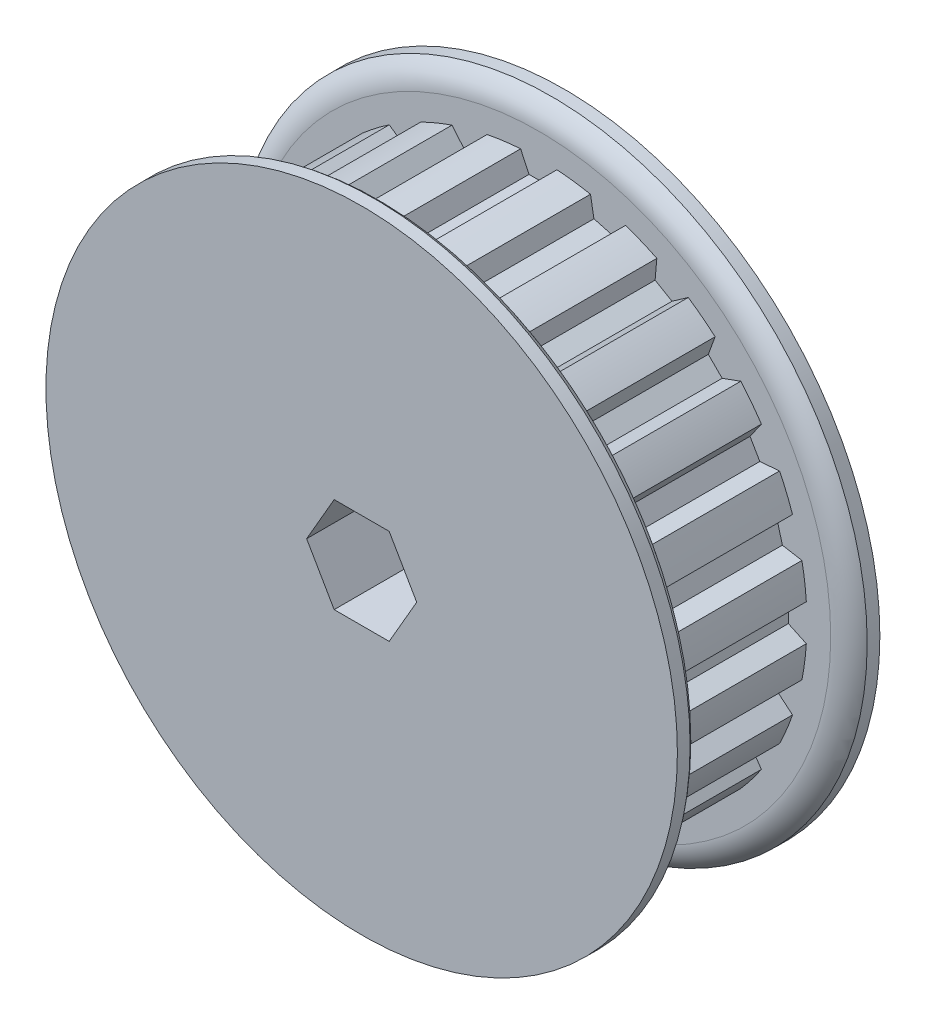
from build123d import *

# Parameters (mm, degrees)
CUT_EXTRUDE1_START = 1.397
CUT_EXTRUDE1_DEPTH = 10.7188
CIRPATTERN1_COUNT  = 24
SKETCH4_R          = 1.5875
CUT_EXTRUDE2_DEPTH = 34.439119294
CUT_EXTRUDE3_DEPTH = 1.190625
CIRPATTERN2_COUNT  = 2
CIRPATTERN2_ANGLE  = 90
SKETCH7_R          = 13.5001
CUT_EXTRUDE4_DEPTH = 7.9248
CUT_EXTRUDE5_DEPTH = 35.629218341


with BuildPart() as part:
    # Sketch2 → Revolve1 (revolve)
    with BuildSketch(Plane(origin=(0, 0, 0), x_dir=(0, 0, -1), z_dir=(1, 0, 0)), mode=Mode.PRIVATE) as revolve1_sk:
        with BuildLine():
            Line((-11.1125, 3.175), (11.1125, 3.175))
            Line((11.1125, 3.175), (11.1125, 22.3012))
            Line((11.1125, 22.3012), (10.21715, 22.3012))
            ThreePointArc((10.21715, 22.3012), (9.559608575, 21.573014266), (9.3218, 20.621141234))
            Line((9.3218, 20.621141234), (9.3218, 18.941082468))
            Line((9.3218, 18.941082468), (-1.397, 18.941082468))
            Line((-1.397, 18.941082468), (-1.397, 20.621141234))
            ThreePointArc((-1.397, 20.621141234), (-1.634808575, 21.573014266), (-2.29235, 22.3012))
            Line((-2.29235, 22.3012), (-3.1877, 22.3012))
            Line((-3.1877, 22.3012), (-3.1877, 13.5001))
            Line((-3.1877, 13.5001), (-11.1125, 13.5001))
            Line((-11.1125, 13.5001), (-11.1125, 3.175))
        make_face()
    revolve(revolve1_sk.sketch.rotate(Axis((0, 0, 11.1125), (0, 0, -1)), 90), axis=Axis((0, 0, 11.1125), (0, 0, -1)))

    # Sketch3 → Cut-Extrude1 (cut)
    with BuildSketch(Plane.XY.offset(CUT_EXTRUDE1_START)):
        with BuildLine():
            Line((-0.690489274, 17.6276), (0.690489274, 17.6276))
            Line((0.690489274, 17.6276), (1.2827, 18.8976))
            ThreePointArc((1.2827, 18.8976), (0, 18.941082468), (-1.2827, 18.8976))
            Line((-1.2827, 18.8976), (-0.690489274, 17.6276))
        make_face()
    cut_extrude1 = extrude(amount=-CUT_EXTRUDE1_DEPTH, mode=Mode.SUBTRACT)

    # CirPattern1: Cut-Extrude1 ×24 about axis
    cirpattern1_axis = Axis((0, 0, 0), (0, 0, 1))
    for i in range(1, CIRPATTERN1_COUNT):
        add(cut_extrude1.rotate(cirpattern1_axis, i * 360 / CIRPATTERN1_COUNT), mode=Mode.SUBTRACT)

    # Sketch4 → Cut-Extrude2 (cut, through all)
    with BuildSketch(Plane(origin=(0, 0, 0), x_dir=(1, 0, 0), z_dir=(0, 1, 0))):
        with Locations(Location((0, -7.1501, 0), (0, 0, 90))):
            Circle(SKETCH4_R)
    cut_extrude2 = extrude(amount=CUT_EXTRUDE2_DEPTH, mode=Mode.SUBTRACT)

    # Sketch5 → Revolve2 (revolve)
    with BuildSketch(Plane.XY.offset(7.1501), mode=Mode.PRIVATE) as revolve2_sk:
        Polygon((1.0795, 13.406436654), (1.5875, 12.898436654), (1.5875, 3.81), (0.9525, 3.175), (0, 3.175), (0, 13.406436654), align=None)
    revolve2 = revolve(revolve2_sk.sketch.rotate(Axis((0, 0, 7.1501), (0, 1, 0)), 90), axis=Axis((0, 0, 7.1501), (0, 1, 0)))

    # Sketch6 → Cut-Extrude3 (cut)
    with BuildSketch(Plane(origin=(0, 13.406436654, 0), x_dir=(1, 0, 0), z_dir=(0, 1, 0))):
        Polygon((0, -6.233556448), (-0.79375, -6.691828224), (-0.79375, -7.608371776), (0, -8.066643552), (0.79375, -7.608371776), (0.79375, -6.691828224), align=None)
    cut_extrude3 = extrude(amount=-CUT_EXTRUDE3_DEPTH, mode=Mode.SUBTRACT)

    # CirPattern2: Cut-Extrude2, Revolve2, Cut-Extrude3 ×2 about axis
    cirpattern2_axis = Axis((0, 0, 0), (0, 0, -1))
    add([cut_extrude2.rotate(cirpattern2_axis, i * CIRPATTERN2_ANGLE / (CIRPATTERN2_COUNT - 1)) for i in range(1, CIRPATTERN2_COUNT)], mode=Mode.SUBTRACT)
    add([revolve2.rotate(cirpattern2_axis, i * CIRPATTERN2_ANGLE / (CIRPATTERN2_COUNT - 1)) for i in range(1, CIRPATTERN2_COUNT)])
    add([cut_extrude3.rotate(cirpattern2_axis, i * CIRPATTERN2_ANGLE / (CIRPATTERN2_COUNT - 1)) for i in range(1, CIRPATTERN2_COUNT)], mode=Mode.SUBTRACT)

    # Sketch7 → Cut-Extrude4 (cut)
    with BuildSketch(Plane.XY.offset(11.1125)):
        Circle(SKETCH7_R)
    extrude(amount=-CUT_EXTRUDE4_DEPTH, mode=Mode.SUBTRACT)

    # Sketch8 → Cut-Extrude5 (cut, through all)
    with BuildSketch(Plane.XY.offset(3.1877)):
        Polygon((3.886144662, 0), (1.943072331, 3.3655), (-1.943072331, 3.3655), (-3.886144662, 0), (-1.943072331, -3.3655), (1.943072331, -3.3655), align=None)
    extrude(amount=-CUT_EXTRUDE5_DEPTH, mode=Mode.SUBTRACT)


solid = part.part
